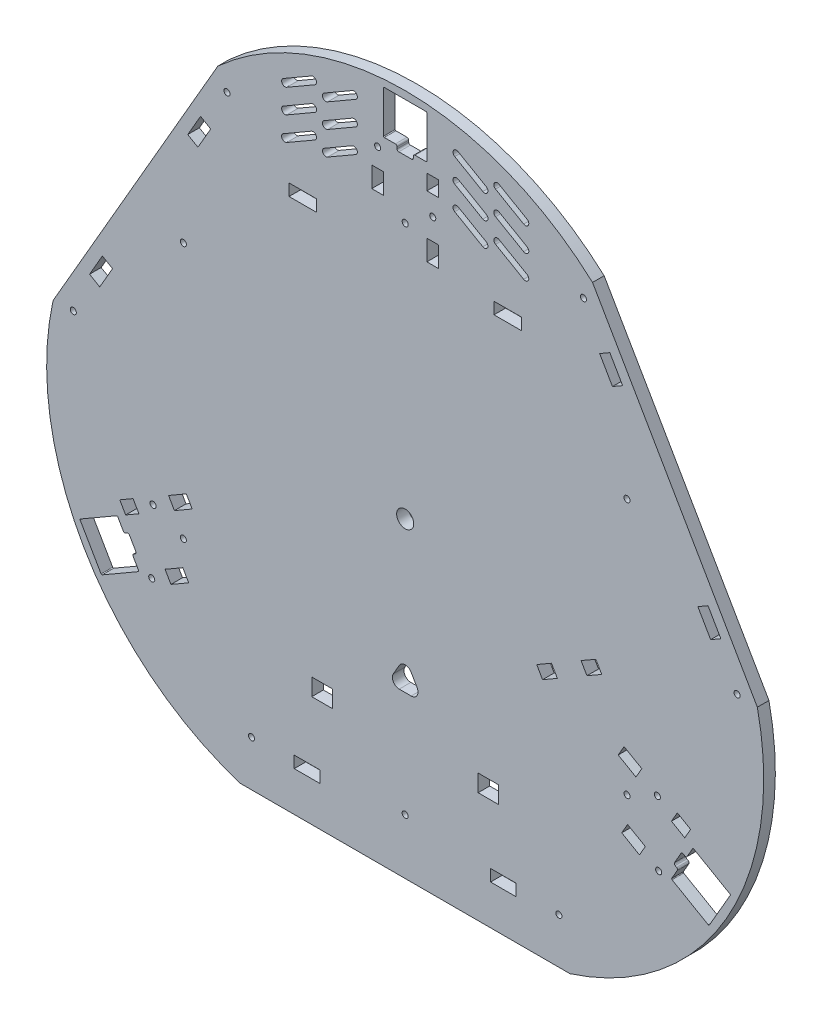
from build123d import *

# Parameters (mm, degrees)
SKETCH1_R                = 5
BOSS_EXTRUDE1_DEPTH      = 6.8
SKETCH2_R                = 1.775
SKETCH2_W                = 15
SKETCH2_H                = 6.88
CUT_EXTRUDE1_DEPTH       = 6.8
SKETCH3_R                = 1.775
CUT_EXTRUDE2_DEPTH       = 6.8
FILLET1_R                = 0.5
FILLET2_R                = 1
FILLET1_OF_MIRROR1_R     = 0.5
FILLET2_OF_MIRROR1_R     = 1
CIRPATTERN1_COUNT        = 3
FILLET1_OF_CIRPATTERN1_R = 0.5
FILLET2_OF_CIRPATTERN1_R = 1
SKETCH4_R                = 1.775
CUT_EXTRUDE3_DEPTH       = 6.8
CIRPATTERN2_COUNT        = 6
CUT_EXTRUDE4_DEPTH       = 6.8
LPATTERN1_COUNT          = 3
LPATTERN1_PITCH          = 14
MIRROR2_COPY_1_DEPTH     = 6.8
MIRROR2_COPY_2_DEPTH     = 6.8
SKETCH6_W                = 16
SKETCH6_H                = 6.88
CUT_EXTRUDE5_DEPTH       = 6.8
SKETCH7_W                = 12
SKETCH7_H                = 10
CUT_EXTRUDE6_DEPTH       = 6.8
CUT_EXTRUDE8_DEPTH       = 6.8
CUT_EXTRUDE10_DEPTH      = 7.8


with BuildPart() as part:
    # Sketch1 → Boss-Extrude1 (new body)
    with BuildSketch(Plane.XY):
        with BuildLine():
            Line((-96.50625, -182.3938), (96.50625, -182.3938))
            ThreePointArc((96.50625, -182.3938), (188.11551, -108.60854), (206.210789, 7.620036))
            Line((206.210789, 7.620036), (109.704539, 174.773764))
            ThreePointArc((109.704539, 174.773764), (0, 217.21708), (-109.704539, 174.773764))
            Line((-109.704539, 174.773764), (-206.210789, 7.620036))
            ThreePointArc((-206.210789, 7.620036), (-188.11551, -108.60854), (-96.50625, -182.3938))
        make_face()
        Circle(SKETCH1_R, mode=Mode.SUBTRACT)
    extrude(amount=BOSS_EXTRUDE1_DEPTH)

    # Sketch2 → Cut-Extrude1 (cut)
    with BuildSketch(Plane.XY.offset(6.8)):
        Polygon((-177.328499, 44.64563), (-171.370244, 41.20563), (-178.870244, 28.215249), (-184.828499, 31.655249), align=None)
        with Locations((-194.349372, 8.284614)):
            Circle(SKETCH2_R)
        Polygon((-127.328499, 131.24817), (-119.828499, 144.238551), (-113.870244, 140.798551), (-121.370244, 127.80817), align=None)
        with Locations((-104.349372, 164.169186)):
            Circle(SKETCH2_R)
        with Locations((104.349372, 164.169186)):
            Circle(SKETCH2_R)
        Polygon((121.370244, 127.80817), (113.870244, 140.798551), (119.828499, 144.238551), (127.328499, 131.24817), align=None)
        Polygon((178.870244, 28.215249), (171.370244, 41.20563), (177.328499, 44.64563), (184.828499, 31.655249), align=None)
        with Locations((194.349372, 8.284614)):
            Circle(SKETCH2_R)
        with Locations((57.5, -155.7038)):
            Rectangle(SKETCH2_W, SKETCH2_H)
        with Locations((90, -155.7038)):
            Circle(SKETCH2_R)
        with Locations((-57.5, -155.7038)):
            Rectangle(SKETCH2_W, SKETCH2_H)
        with Locations((-90, -155.7038)):
            Circle(SKETCH2_R)
    extrude(amount=-CUT_EXTRUDE1_DEPTH, mode=Mode.SUBTRACT)

    # Sketch3 → Cut-Extrude2 (cut)
    with BuildSketch(Plane.XY.offset(6.8)):
        with Locations((-147.65788, -66.61345)):
            Circle(SKETCH3_R)
        with Locations((-148.42079, -104.32765)):
            Circle(SKETCH3_R)
        Polygon((-190.553603, -95.351477), (-177.853603, -117.348523), (-155.856558, -104.648523), (-159.831558, -97.763621), (-157.233482, -96.263621), (-161.983482, -88.036379), (-164.581558, -89.536379), (-168.556558, -82.651477), align=None)
        Polygon((-167.146816, -73.893223), (-159.352587, -69.393223), (-155.912587, -75.351477), (-163.706816, -79.851477), align=None)
        Polygon((-128.175673, -51.393223), (-138.567978, -57.393223), (-135.127978, -63.351477), (-124.735673, -57.351477), align=None)
        Polygon((-140.614511, -95.848523), (-137.174511, -101.806777), (-126.782206, -95.806777), (-130.222206, -89.848523), align=None)
    cut_extrude2 = extrude(amount=-CUT_EXTRUDE2_DEPTH, mode=Mode.SUBTRACT)

    # Fillet1
    fillet1_edges = [part.edges().sort_by_distance(p)[0] for p in [
        (-190.553603, -95.351477, 3.4),
        (-168.556558, -82.651477, 3.4),
        (-155.856558, -104.648523, 3.4),
        (-177.853603, -117.348523, 3.4),
    ]]
    fillet(fillet1_edges, radius=FILLET1_R)

    # Fillet2
    fillet2_edges = [part.edges().sort_by_distance(p)[0] for p in [
        (-164.581558, -89.536379, 3.4),
        (-161.983482, -88.036379, 3.4),
        (-157.233482, -96.263621, 3.4),
        (-159.831558, -97.763621, 3.4),
    ]]
    fillet(fillet2_edges, radius=FILLET2_R)

    # Mirror1: Cut-Extrude2 across plane
    add(cut_extrude2.mirror(Plane(origin=(0, 0, 0), x_dir=(0, 0, 1), z_dir=(1, 0, 0))), mode=Mode.SUBTRACT)

    # Fillet1 of Mirror1
    fillet1_of_mirror1_edges = [part.edges().sort_by_distance(p)[0] for p in [
        (190.553603, -95.351477, 3.4),
        (168.556558, -82.651477, 3.4),
        (155.856558, -104.648523, 3.4),
        (177.853603, -117.348523, 3.4),
    ]]
    fillet(fillet1_of_mirror1_edges, radius=FILLET1_OF_MIRROR1_R)

    # Fillet2 of Mirror1
    fillet2_of_mirror1_edges = [part.edges().sort_by_distance(p)[0] for p in [
        (164.581558, -89.536379, 3.4),
        (161.983482, -88.036379, 3.4),
        (157.233482, -96.263621, 3.4),
        (159.831558, -97.763621, 3.4),
    ]]
    fillet(fillet2_of_mirror1_edges, radius=FILLET2_OF_MIRROR1_R)

    # CirPattern1: Cut-Extrude2 ×3 about axis, 1 skipped
    cirpattern1_axis = Axis((0, 0, 6.8), (0, 0, 1))
    add([cut_extrude2.rotate(cirpattern1_axis, i * 360 / CIRPATTERN1_COUNT) for i in range(1, CIRPATTERN1_COUNT) if i not in (1,)], mode=Mode.SUBTRACT)

    # Fillet1 of CirPattern1
    fillet1_of_cirpattern1_edges = [part.edges().sort_by_distance(p)[0] for p in [
        (12.7, 212.7, 3.4),
        (12.7, 187.3, 3.4),
        (-12.7, 187.3, 3.4),
        (-12.7, 212.7, 3.4),
    ]]
    fillet(fillet1_of_cirpattern1_edges, radius=FILLET1_OF_CIRPATTERN1_R)

    # Fillet2 of CirPattern1
    fillet2_of_cirpattern1_edges = [part.edges().sort_by_distance(p)[0] for p in [
        (4.75, 187.3, 3.4),
        (4.75, 184.3, 3.4),
        (-4.75, 184.3, 3.4),
        (-4.75, 187.3, 3.4),
    ]]
    fillet(fillet2_of_cirpattern1_edges, radius=FILLET2_OF_CIRPATTERN1_R)

    # Sketch4 → Cut-Extrude3 (cut)
    with BuildSketch(Plane.XY.offset(6.8)):
        with Locations((0, 150)):
            Circle(SKETCH4_R)
    cut_extrude3 = extrude(amount=-CUT_EXTRUDE3_DEPTH, mode=Mode.SUBTRACT)

    # CirPattern2: Cut-Extrude3 ×6 about axis
    cirpattern2_axis = Axis((0, 0, 0), (0, 0, 1))
    for i in range(1, CIRPATTERN2_COUNT):
        add(cut_extrude3.rotate(cirpattern2_axis, i * 360 / CIRPATTERN2_COUNT), mode=Mode.SUBTRACT)

    # Sketch5 → Cut-Extrude4 (cut)
    with BuildSketch(Plane.XY.offset(6.8)):
        with BuildLine():
            Line((-29, 198.267949), (-45.454483, 188.767949))
            ThreePointArc((-45.454483, 188.767949), (-48.186533, 189.5), (-47.454483, 192.232051))
            Line((-47.454483, 192.232051), (-31, 201.732051))
            ThreePointArc((-31, 201.732051), (-28.267949, 201), (-29, 198.267949))
        make_face()
        with BuildLine():
            Line((-52.918584, 193.696152), (-69.373067, 184.196152))
            ThreePointArc((-69.373067, 184.196152), (-72.105118, 184.928203), (-71.373067, 187.660254))
            Line((-71.373067, 187.660254), (-54.918584, 197.160254))
            ThreePointArc((-54.918584, 197.160254), (-52.186533, 196.428203), (-52.918584, 193.696152))
        make_face()
    cut_extrude4 = extrude(amount=-CUT_EXTRUDE4_DEPTH, mode=Mode.SUBTRACT)

    # LPattern1: Cut-Extrude4 ×3
    with Locations(*[(0, -i * LPATTERN1_PITCH, 0) for i in range(1, LPATTERN1_COUNT)]):
        add(cut_extrude4, mode=Mode.SUBTRACT)

    # Mirror2: Cut-Extrude4 across plane
    add(cut_extrude4.mirror(Plane(origin=(0, 0, 0), x_dir=(0, 0, 1), z_dir=(1, 0, 0))), mode=Mode.SUBTRACT)

    # Mirror2 copy 1 sketch → Mirror2 copy 1 (cut)
    with BuildSketch(Plane(origin=(0, -14, 6.8), x_dir=(-1, 0, 0), z_dir=(0, 0, 1))):
        with BuildLine():
            Line((-29, -198.267949), (-45.454483, -188.767949))
            ThreePointArc((-45.454483, -188.767949), (-48.186533, -189.5), (-47.454483, -192.232051))
            Line((-47.454483, -192.232051), (-31, -201.732051))
            ThreePointArc((-31, -201.732051), (-28.267949, -201), (-29, -198.267949))
        make_face()
        with BuildLine():
            Line((-52.918584, -193.696152), (-69.373067, -184.196152))
            ThreePointArc((-69.373067, -184.196152), (-72.105118, -184.928203), (-71.373067, -187.660254))
            Line((-71.373067, -187.660254), (-54.918584, -197.160254))
            ThreePointArc((-54.918584, -197.160254), (-52.186533, -196.428203), (-52.918584, -193.696152))
        make_face()
    extrude(amount=-MIRROR2_COPY_1_DEPTH, mode=Mode.SUBTRACT)

    # Mirror2 copy 2 sketch → Mirror2 copy 2 (cut)
    with BuildSketch(Plane(origin=(0, -28, 6.8), x_dir=(-1, 0, 0), z_dir=(0, 0, 1))):
        with BuildLine():
            Line((-29, -198.267949), (-45.454483, -188.767949))
            ThreePointArc((-45.454483, -188.767949), (-48.186533, -189.5), (-47.454483, -192.232051))
            Line((-47.454483, -192.232051), (-31, -201.732051))
            ThreePointArc((-31, -201.732051), (-28.267949, -201), (-29, -198.267949))
        make_face()
        with BuildLine():
            Line((-52.918584, -193.696152), (-69.373067, -184.196152))
            ThreePointArc((-69.373067, -184.196152), (-72.105118, -184.928203), (-71.373067, -187.660254))
            Line((-71.373067, -187.660254), (-54.918584, -197.160254))
            ThreePointArc((-54.918584, -197.160254), (-52.186533, -196.428203), (-52.918584, -193.696152))
        make_face()
    extrude(amount=-MIRROR2_COPY_2_DEPTH, mode=Mode.SUBTRACT)

    # Sketch6 → Cut-Extrude5 (cut)
    with BuildSketch(Plane.XY.offset(6.8)):
        with Locations((60, 132.94)):
            Rectangle(SKETCH6_W, SKETCH6_H)
        with Locations((-60, 132.94)):
            Rectangle(SKETCH6_W, SKETCH6_H)
    extrude(amount=-CUT_EXTRUDE5_DEPTH, mode=Mode.SUBTRACT)

    # Sketch7 → Cut-Extrude6 (cut)
    with BuildSketch(Plane.XY.offset(6.8)):
        with Locations((-48.7, -112.5138)):
            Rectangle(SKETCH7_W, SKETCH7_H)
        with Locations((48.7, -112.5138)):
            Rectangle(SKETCH7_W, SKETCH7_H)
    extrude(amount=-CUT_EXTRUDE6_DEPTH, mode=Mode.SUBTRACT)

    # Sketch8 → Cut-Extrude8 (cut)
    with BuildSketch(Plane.XY.offset(6.8)):
        with BuildLine():
            Line((-3.464102, -76), (-6.964102, -82.062178))
            ThreePointArc((-6.964102, -82.062178), (-6.964102, -86.062178), (-3.5, -88.062178))
            Line((-3.5, -88.062178), (3.5, -88.062178))
            ThreePointArc((3.5, -88.062178), (6.964102, -86.062178), (6.964102, -82.062178))
            Line((6.964102, -82.062178), (3.464102, -76))
            ThreePointArc((3.464102, -76), (0, -74), (-3.464102, -76))
        make_face()
    extrude(amount=-CUT_EXTRUDE8_DEPTH, mode=Mode.SUBTRACT)

    # Sketch10 → Cut-Extrude10 (cut, through all)
    with BuildSketch(Plane.XY.offset(6.8)):
        Polygon((111.648212, -15.352776), (115.088212, -21.311031), (106.427958, -26.311031), (102.987958, -20.352776), align=None)
        Polygon((85.66745, -30.352776), (89.10745, -36.311031), (80.447196, -41.311031), (77.007196, -35.352776), align=None)
    extrude(amount=-CUT_EXTRUDE10_DEPTH, mode=Mode.SUBTRACT)


solid = part.part
